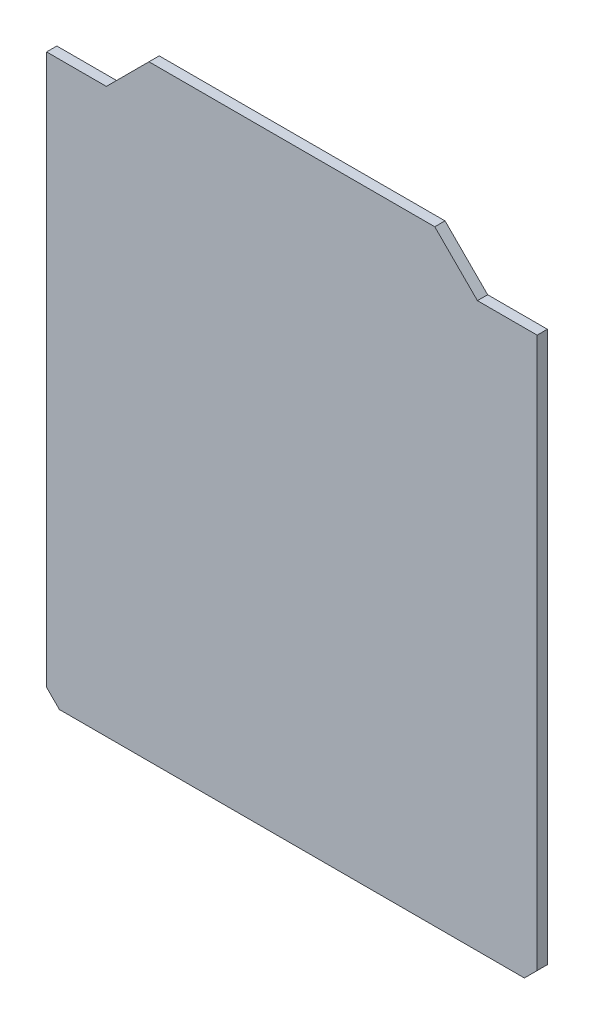
from build123d import *

# Parameters (mm, degrees)
EXTRUDE_1_DEPTH = 1.2
CHAMFER_1_SIZE  = 1.5


with BuildPart() as part:
    # 草图1 → 凸台-拉伸1 (new body)
    with BuildSketch(Plane.XY):
        Polygon((-21.299595232, 40.59338459), (-16.299595232, 45.59338459), (17.200404768, 45.59338459), (22.200404768, 40.59338459), (29.200404768, 40.59338459), (29.200404768, -25.414429895), (-28.299595232, -25.414429895), (-28.299595232, 40.59338459), align=None)
    extrude(amount=EXTRUDE_1_DEPTH)

    # 倒角1
    chamfer_1_edges = [part.edges().sort_by_distance(p)[0] for p in [
        (29.200404768, -25.414429895, 0.6),
        (-28.299595232, -25.414429895, 0.6),
    ]]
    chamfer(chamfer_1_edges, length=CHAMFER_1_SIZE)


solid = part.part
